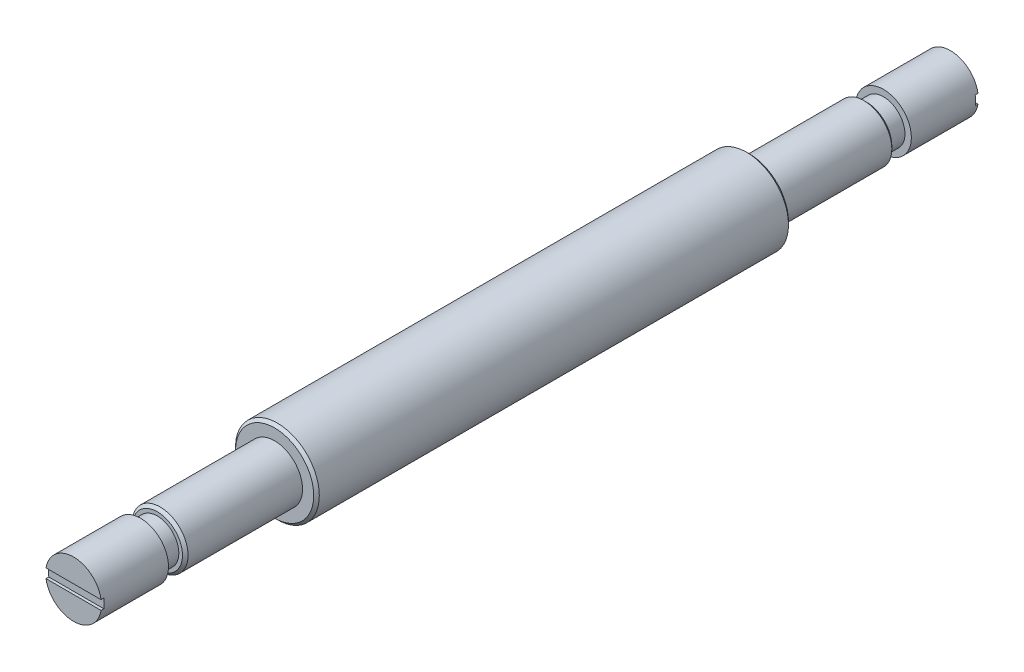
from build123d import *

# Parameters (mm, degrees)
ESQUISSE2_W             = 3
ESQUISSE2_H             = 3.85
CHANFREIN1_SIZE         = 0.5
ESQUISSE4_W             = 11.666620124
ESQUISSE4_H             = 1.663113932
ENL_V_MAT_EXTRU_2_DEPTH = 0.5


with BuildPart() as part:
    # Esquisse2 → Révolution1 (revolve)
    with BuildSketch(Plane(origin=(0, 0, 0), x_dir=(0, 0, -1), z_dir=(1, 0, 0))):
        Polygon((-78.5, 0), (-66.5, 0), (-66.5, 3.85), (-66.5, 5), (-78.5, 5), align=None)
        with Locations((-65, 1.925)):
            Rectangle(ESQUISSE2_W, ESQUISSE2_H)
        Polygon((-63.5, 3.85), (-63.5, 0), (-42.5, 0), (-42.5, 5), (-63.5, 5), align=None)
        Polygon((-42.5, 5), (-42.5, 0), (0, 0), (0, 7.5), (-42.5, 7.5), align=None)
        Polygon((0, 7.5), (0, 0), (42.5, 0), (42.5, 5), (42.5, 7.5), align=None)
        Polygon((42.5, 5), (42.5, 0), (63.5, 0), (63.5, 3.85), (63.5, 5), align=None)
        with Locations((65, 1.925)):
            Rectangle(ESQUISSE2_W, ESQUISSE2_H)
        Polygon((66.5, 3.85), (66.5, 0), (78.5, 0), (78.5, 5), (66.5, 5), align=None)
    revolve(axis=Axis((0, 0, 42.5), (0, 0, -1)))

    # Chanfrein1
    chanfrein1_edges = [part.edges().sort_by_distance(p)[0] for p in [
        (0, -5, 63.5),
        (0, -7.5, 42.5),
        (0, -7.5, -42.5),
        (0, -5, -63.5),
    ]]
    chamfer(chanfrein1_edges, length=CHANFREIN1_SIZE)

    # Esquisse4 → Enlèv. mat.-Extru.2 (cut)
    with BuildSketch(Plane(origin=(0, 0, -78.5), x_dir=(-1, 0, 0), z_dir=(0, 0, -1))):
        Rectangle(ESQUISSE4_W, ESQUISSE4_H)
    enl_v_mat_extru_2 = extrude(amount=-ENL_V_MAT_EXTRU_2_DEPTH, mode=Mode.SUBTRACT)

    # Symétrie2: Enlèv. mat.-Extru.2 across plane
    add(enl_v_mat_extru_2.mirror(Plane.XY), mode=Mode.SUBTRACT)


solid = part.part
